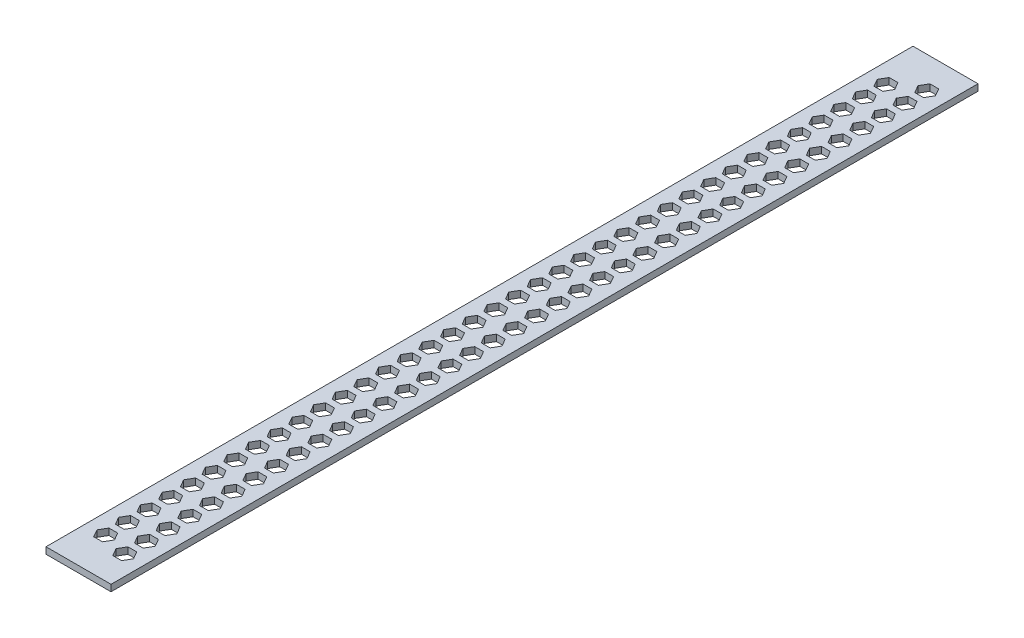
from build123d import *

# Parameters (mm, degrees)
SKETCH1_W           = 30
SKETCH1_H           = 400
BOSS_EXTRUDE1_DEPTH = 3
CUT_EXTRUDE1_DEPTH  = 4


with BuildPart() as part:
    # Sketch1 → Boss-Extrude1 (new body)
    with BuildSketch(Plane(origin=(0, 0, 0), x_dir=(1, 0, 0), z_dir=(0, 1, 0))):
        with Locations((-21.516129032, 112.756272401)):
            Rectangle(SKETCH1_W, SKETCH1_H)
    extrude(amount=BOSS_EXTRUDE1_DEPTH)

    # Sketch2 → Cut-Extrude1 (cut, through all)
    with BuildSketch(Plane(origin=(0, 0, 0), x_dir=(-1, 0, 0), z_dir=(0, -1, 0))):
        Polygon((11.516129032, -71.863388881), (13.536854974, -75.363388881), (17.578306859, -75.363388881), (19.599032801, -71.863388881), (17.578306859, -68.363388881), (13.536854974, -68.363388881), align=None)
        Polygon((13.536854974, -58.363388881), (11.516129032, -61.863388881), (13.536854974, -65.363388881), (17.578306859, -65.363388881), (19.599032801, -61.863388881), (17.578306859, -58.363388881), align=None)
        Polygon((25.453951206, -72.243727599), (29.49540309, -72.243727599), (31.516129032, -68.743727599), (29.49540309, -65.243727599), (25.453951206, -65.243727599), (23.433225264, -68.743727599), align=None)
        Polygon((13.536854974, -48.363388881), (11.516129032, -51.863388881), (13.536854974, -55.363388881), (17.578306859, -55.363388881), (19.599032801, -51.863388881), (17.578306859, -48.363388881), align=None)
        Polygon((25.453951206, -62.243727599), (29.49540309, -62.243727599), (31.516129032, -58.743727599), (29.49540309, -55.243727599), (25.453951206, -55.243727599), (23.433225264, -58.743727599), align=None)
        Polygon((13.536854974, -38.363388881), (11.516129032, -41.863388881), (13.536854974, -45.363388881), (17.578306859, -45.363388881), (19.599032801, -41.863388881), (17.578306859, -38.363388881), align=None)
        Polygon((25.453951206, -52.243727599), (29.49540309, -52.243727599), (31.516129032, -48.743727599), (29.49540309, -45.243727599), (25.453951206, -45.243727599), (23.433225264, -48.743727599), align=None)
        Polygon((13.536854974, -28.363388881), (11.516129032, -31.863388881), (13.536854974, -35.363388881), (17.578306859, -35.363388881), (19.599032801, -31.863388881), (17.578306859, -28.363388881), align=None)
        Polygon((25.453951206, -42.243727599), (29.49540309, -42.243727599), (31.516129032, -38.743727599), (29.49540309, -35.243727599), (25.453951206, -35.243727599), (23.433225264, -38.743727599), align=None)
        Polygon((13.536854974, -18.363388881), (11.516129032, -21.863388881), (13.536854974, -25.363388881), (17.578306859, -25.363388881), (19.599032801, -21.863388881), (17.578306859, -18.363388881), align=None)
        Polygon((25.453951206, -32.243727599), (29.49540309, -32.243727599), (31.516129032, -28.743727599), (29.49540309, -25.243727599), (25.453951206, -25.243727599), (23.433225264, -28.743727599), align=None)
        Polygon((13.536854974, -8.363388881), (11.516129032, -11.863388881), (13.536854974, -15.363388881), (17.578306859, -15.363388881), (19.599032801, -11.863388881), (17.578306859, -8.363388881), align=None)
        Polygon((25.453951206, -22.243727599), (29.49540309, -22.243727599), (31.516129032, -18.743727599), (29.49540309, -15.243727599), (25.453951206, -15.243727599), (23.433225264, -18.743727599), align=None)
        Polygon((13.536854974, 1.636611119), (11.516129032, -1.863388881), (13.536854974, -5.363388881), (17.578306859, -5.363388881), (19.599032801, -1.863388881), (17.578306859, 1.636611119), align=None)
        Polygon((25.453951206, -12.243727599), (29.49540309, -12.243727599), (31.516129032, -8.743727599), (29.49540309, -5.243727599), (25.453951206, -5.243727599), (23.433225264, -8.743727599), align=None)
        Polygon((13.536854974, 11.636611119), (11.516129032, 8.136611119), (13.536854974, 4.636611119), (17.578306859, 4.636611119), (19.599032801, 8.136611119), (17.578306859, 11.636611119), align=None)
        Polygon((25.453951206, -2.243727599), (29.49540309, -2.243727599), (31.516129032, 1.256272401), (29.49540309, 4.756272401), (25.453951206, 4.756272401), (23.433225264, 1.256272401), align=None)
        Polygon((13.536854974, 21.636611119), (11.516129032, 18.136611119), (13.536854974, 14.636611119), (17.578306859, 14.636611119), (19.599032801, 18.136611119), (17.578306859, 21.636611119), align=None)
        Polygon((25.453951206, 7.756272401), (29.49540309, 7.756272401), (31.516129032, 11.256272401), (29.49540309, 14.756272401), (25.453951206, 14.756272401), (23.433225264, 11.256272401), align=None)
        Polygon((13.536854974, 31.636611119), (11.516129032, 28.136611119), (13.536854974, 24.636611119), (17.578306859, 24.636611119), (19.599032801, 28.136611119), (17.578306859, 31.636611119), align=None)
        Polygon((25.453951206, 17.756272401), (29.49540309, 17.756272401), (31.516129032, 21.256272401), (29.49540309, 24.756272401), (25.453951206, 24.756272401), (23.433225264, 21.256272401), align=None)
        Polygon((13.536854974, 41.636611119), (11.516129032, 38.136611119), (13.536854974, 34.636611119), (17.578306859, 34.636611119), (19.599032801, 38.136611119), (17.578306859, 41.636611119), align=None)
        Polygon((25.453951206, 27.756272401), (29.49540309, 27.756272401), (31.516129032, 31.256272401), (29.49540309, 34.756272401), (25.453951206, 34.756272401), (23.433225264, 31.256272401), align=None)
        Polygon((13.536854974, 51.636611119), (11.516129032, 48.136611119), (13.536854974, 44.636611119), (17.578306859, 44.636611119), (19.599032801, 48.136611119), (17.578306859, 51.636611119), align=None)
        Polygon((25.453951206, 37.756272401), (29.49540309, 37.756272401), (31.516129032, 41.256272401), (29.49540309, 44.756272401), (25.453951206, 44.756272401), (23.433225264, 41.256272401), align=None)
        Polygon((13.536854974, 61.636611119), (11.516129032, 58.136611119), (13.536854974, 54.636611119), (17.578306859, 54.636611119), (19.599032801, 58.136611119), (17.578306859, 61.636611119), align=None)
        Polygon((25.453951206, 47.756272401), (29.49540309, 47.756272401), (31.516129032, 51.256272401), (29.49540309, 54.756272401), (25.453951206, 54.756272401), (23.433225264, 51.256272401), align=None)
        Polygon((13.536854974, 71.636611119), (11.516129032, 68.136611119), (13.536854974, 64.636611119), (17.578306859, 64.636611119), (19.599032801, 68.136611119), (17.578306859, 71.636611119), align=None)
        Polygon((25.453951206, 57.756272401), (29.49540309, 57.756272401), (31.516129032, 61.256272401), (29.49540309, 64.756272401), (25.453951206, 64.756272401), (23.433225264, 61.256272401), align=None)
        Polygon((13.536854974, 81.636611119), (11.516129032, 78.136611119), (13.536854974, 74.636611119), (17.578306859, 74.636611119), (19.599032801, 78.136611119), (17.578306859, 81.636611119), align=None)
        Polygon((25.453951206, 67.756272401), (29.49540309, 67.756272401), (31.516129032, 71.256272401), (29.49540309, 74.756272401), (25.453951206, 74.756272401), (23.433225264, 71.256272401), align=None)
        Polygon((13.536854974, 91.636611119), (11.516129032, 88.136611119), (13.536854974, 84.636611119), (17.578306859, 84.636611119), (19.599032801, 88.136611119), (17.578306859, 91.636611119), align=None)
        Polygon((25.453951206, 77.756272401), (29.49540309, 77.756272401), (31.516129032, 81.256272401), (29.49540309, 84.756272401), (25.453951206, 84.756272401), (23.433225264, 81.256272401), align=None)
        Polygon((13.536854974, 101.636611119), (11.516129032, 98.136611119), (13.536854974, 94.636611119), (17.578306859, 94.636611119), (19.599032801, 98.136611119), (17.578306859, 101.636611119), align=None)
        Polygon((25.453951206, 87.756272401), (29.49540309, 87.756272401), (31.516129032, 91.256272401), (29.49540309, 94.756272401), (25.453951206, 94.756272401), (23.433225264, 91.256272401), align=None)
        Polygon((13.536854974, 111.636611119), (11.516129032, 108.136611119), (13.536854974, 104.636611119), (17.578306859, 104.636611119), (19.599032801, 108.136611119), (17.578306859, 111.636611119), align=None)
        Polygon((25.453951206, 97.756272401), (29.49540309, 97.756272401), (31.516129032, 101.256272401), (29.49540309, 104.756272401), (25.453951206, 104.756272401), (23.433225264, 101.256272401), align=None)
        Polygon((13.536854974, 121.636611119), (11.516129032, 118.136611119), (13.536854974, 114.636611119), (17.578306859, 114.636611119), (19.599032801, 118.136611119), (17.578306859, 121.636611119), align=None)
        Polygon((25.453951206, 107.756272401), (29.49540309, 107.756272401), (31.516129032, 111.256272401), (29.49540309, 114.756272401), (25.453951206, 114.756272401), (23.433225264, 111.256272401), align=None)
        Polygon((13.536854974, 131.636611119), (11.516129032, 128.136611119), (13.536854974, 124.636611119), (17.578306859, 124.636611119), (19.599032801, 128.136611119), (17.578306859, 131.636611119), align=None)
        Polygon((25.453951206, 117.756272401), (29.49540309, 117.756272401), (31.516129032, 121.256272401), (29.49540309, 124.756272401), (25.453951206, 124.756272401), (23.433225264, 121.256272401), align=None)
        Polygon((13.536854974, 141.636611119), (11.516129032, 138.136611119), (13.536854974, 134.636611119), (17.578306859, 134.636611119), (19.599032801, 138.136611119), (17.578306859, 141.636611119), align=None)
        Polygon((25.453951206, 127.756272401), (29.49540309, 127.756272401), (31.516129032, 131.256272401), (29.49540309, 134.756272401), (25.453951206, 134.756272401), (23.433225264, 131.256272401), align=None)
        Polygon((13.536854974, 151.636611119), (11.516129032, 148.136611119), (13.536854974, 144.636611119), (17.578306859, 144.636611119), (19.599032801, 148.136611119), (17.578306859, 151.636611119), align=None)
        Polygon((25.453951206, 137.756272401), (29.49540309, 137.756272401), (31.516129032, 141.256272401), (29.49540309, 144.756272401), (25.453951206, 144.756272401), (23.433225264, 141.256272401), align=None)
        Polygon((13.536854974, 161.636611119), (11.516129032, 158.136611119), (13.536854974, 154.636611119), (17.578306859, 154.636611119), (19.599032801, 158.136611119), (17.578306859, 161.636611119), align=None)
        Polygon((25.453951206, 147.756272401), (29.49540309, 147.756272401), (31.516129032, 151.256272401), (29.49540309, 154.756272401), (25.453951206, 154.756272401), (23.433225264, 151.256272401), align=None)
        Polygon((13.536854974, 171.636611119), (11.516129032, 168.136611119), (13.536854974, 164.636611119), (17.578306859, 164.636611119), (19.599032801, 168.136611119), (17.578306859, 171.636611119), align=None)
        Polygon((25.453951206, 157.756272401), (29.49540309, 157.756272401), (31.516129032, 161.256272401), (29.49540309, 164.756272401), (25.453951206, 164.756272401), (23.433225264, 161.256272401), align=None)
        Polygon((13.536854974, 181.636611119), (11.516129032, 178.136611119), (13.536854974, 174.636611119), (17.578306859, 174.636611119), (19.599032801, 178.136611119), (17.578306859, 181.636611119), align=None)
        Polygon((25.453951206, 167.756272401), (29.49540309, 167.756272401), (31.516129032, 171.256272401), (29.49540309, 174.756272401), (25.453951206, 174.756272401), (23.433225264, 171.256272401), align=None)
        Polygon((13.536854974, 191.636611119), (11.516129032, 188.136611119), (13.536854974, 184.636611119), (17.578306859, 184.636611119), (19.599032801, 188.136611119), (17.578306859, 191.636611119), align=None)
        Polygon((25.453951206, 177.756272401), (29.49540309, 177.756272401), (31.516129032, 181.256272401), (29.49540309, 184.756272401), (25.453951206, 184.756272401), (23.433225264, 181.256272401), align=None)
        Polygon((13.536854974, 201.636611119), (11.516129032, 198.136611119), (13.536854974, 194.636611119), (17.578306859, 194.636611119), (19.599032801, 198.136611119), (17.578306859, 201.636611119), align=None)
        Polygon((25.453951206, 187.756272401), (29.49540309, 187.756272401), (31.516129032, 191.256272401), (29.49540309, 194.756272401), (25.453951206, 194.756272401), (23.433225264, 191.256272401), align=None)
        Polygon((13.536854974, 211.636611119), (11.516129032, 208.136611119), (13.536854974, 204.636611119), (17.578306859, 204.636611119), (19.599032801, 208.136611119), (17.578306859, 211.636611119), align=None)
        Polygon((25.453951206, 197.756272401), (29.49540309, 197.756272401), (31.516129032, 201.256272401), (29.49540309, 204.756272401), (25.453951206, 204.756272401), (23.433225264, 201.256272401), align=None)
        Polygon((13.536854974, 221.636611119), (11.516129032, 218.136611119), (13.536854974, 214.636611119), (17.578306859, 214.636611119), (19.599032801, 218.136611119), (17.578306859, 221.636611119), align=None)
        Polygon((25.453951206, 207.756272401), (29.49540309, 207.756272401), (31.516129032, 211.256272401), (29.49540309, 214.756272401), (25.453951206, 214.756272401), (23.433225264, 211.256272401), align=None)
        Polygon((13.536854974, 231.636611119), (11.516129032, 228.136611119), (13.536854974, 224.636611119), (17.578306859, 224.636611119), (19.599032801, 228.136611119), (17.578306859, 231.636611119), align=None)
        Polygon((25.453951206, 217.756272401), (29.49540309, 217.756272401), (31.516129032, 221.256272401), (29.49540309, 224.756272401), (25.453951206, 224.756272401), (23.433225264, 221.256272401), align=None)
        Polygon((13.536854974, 241.636611119), (11.516129032, 238.136611119), (13.536854974, 234.636611119), (17.578306859, 234.636611119), (19.599032801, 238.136611119), (17.578306859, 241.636611119), align=None)
        Polygon((25.453951206, 227.756272401), (29.49540309, 227.756272401), (31.516129032, 231.256272401), (29.49540309, 234.756272401), (25.453951206, 234.756272401), (23.433225264, 231.256272401), align=None)
        Polygon((13.536854974, 251.636611119), (11.516129032, 248.136611119), (13.536854974, 244.636611119), (17.578306859, 244.636611119), (19.599032801, 248.136611119), (17.578306859, 251.636611119), align=None)
        Polygon((25.453951206, 237.756272401), (29.49540309, 237.756272401), (31.516129032, 241.256272401), (29.49540309, 244.756272401), (25.453951206, 244.756272401), (23.433225264, 241.256272401), align=None)
        Polygon((13.536854974, 261.636611119), (11.516129032, 258.136611119), (13.536854974, 254.636611119), (17.578306859, 254.636611119), (19.599032801, 258.136611119), (17.578306859, 261.636611119), align=None)
        Polygon((25.453951206, 247.756272401), (29.49540309, 247.756272401), (31.516129032, 251.256272401), (29.49540309, 254.756272401), (25.453951206, 254.756272401), (23.433225264, 251.256272401), align=None)
        Polygon((13.536854974, 271.636611119), (11.516129032, 268.136611119), (13.536854974, 264.636611119), (17.578306859, 264.636611119), (19.599032801, 268.136611119), (17.578306859, 271.636611119), align=None)
        Polygon((25.453951206, 257.756272401), (29.49540309, 257.756272401), (31.516129032, 261.256272401), (29.49540309, 264.756272401), (25.453951206, 264.756272401), (23.433225264, 261.256272401), align=None)
        Polygon((13.536854974, 281.636611119), (11.516129032, 278.136611119), (13.536854974, 274.636611119), (17.578306859, 274.636611119), (19.599032801, 278.136611119), (17.578306859, 281.636611119), align=None)
        Polygon((25.453951206, 267.756272401), (29.49540309, 267.756272401), (31.516129032, 271.256272401), (29.49540309, 274.756272401), (25.453951206, 274.756272401), (23.433225264, 271.256272401), align=None)
        Polygon((13.536854974, 291.636611119), (11.516129032, 288.136611119), (13.536854974, 284.636611119), (17.578306859, 284.636611119), (19.599032801, 288.136611119), (17.578306859, 291.636611119), align=None)
        Polygon((25.453951206, 277.756272401), (29.49540309, 277.756272401), (31.516129032, 281.256272401), (29.49540309, 284.756272401), (25.453951206, 284.756272401), (23.433225264, 281.256272401), align=None)
        Polygon((13.536854974, 301.636611119), (11.516129032, 298.136611119), (13.536854974, 294.636611119), (17.578306859, 294.636611119), (19.599032801, 298.136611119), (17.578306859, 301.636611119), align=None)
        Polygon((25.453951206, 287.756272401), (29.49540309, 287.756272401), (31.516129032, 291.256272401), (29.49540309, 294.756272401), (25.453951206, 294.756272401), (23.433225264, 291.256272401), align=None)
    extrude(amount=-CUT_EXTRUDE1_DEPTH, mode=Mode.SUBTRACT)


solid = part.part
